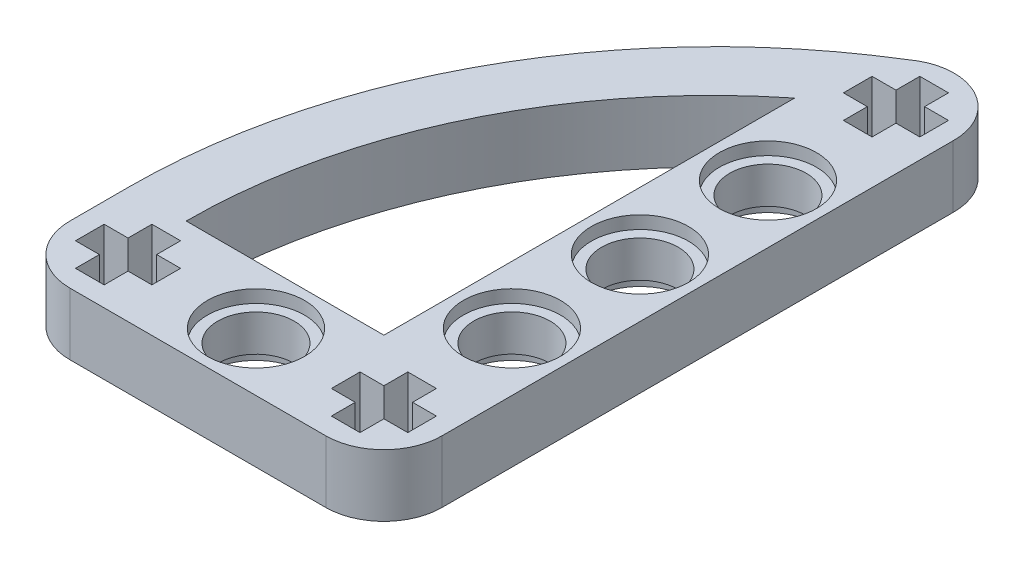
from build123d import *

# Parameters (mm, degrees)
SKETCH1_R           = 2.4
BOSS_EXTRUDE3_DEPTH = 3.9
SKETCH3_R           = 3.05
CUT_EXTRUDE16_DEPTH = 0.8
SKETCH4_R           = 3.05
CUT_EXTRUDE17_DEPTH = 0.8


with BuildPart() as part:
    # Sketch1 → Boss-Extrude3 (new body)
    with BuildSketch(Plane(origin=(0, 0, 0), x_dir=(1, 0, 0), z_dir=(0, 1, 0))):
        with BuildLine():
            Line((-8.030145899, -3.65), (8.039854101, -3.65))
            ThreePointArc((8.039854101, -3.65), (10.620793852, -2.580939751), (11.689854101, 0))
            Line((11.689854101, 0), (11.689854101, 32.1))
            ThreePointArc((11.689854101, 32.1), (9.706187522, 35.407989059), (5.862167957, 35.08980939))
            ThreePointArc((5.862167957, 35.08980939), (-6.996855856, 21.685482921), (-11.680145899, 3.710576637))
            Line((-11.680145899, 3.710576637), (-11.680145899, 0))
            ThreePointArc((-11.680145899, 0), (-10.611085651, -2.580939751), (-8.030145899, -3.65))
        make_face()
        with Locations((0.004854101, 0)):
            Circle(SKETCH1_R, mode=Mode.SUBTRACT)
        with Locations((8.039854101, 24.12)):
            Circle(SKETCH1_R, mode=Mode.SUBTRACT)
        with Locations((8.039854101, 16.08)):
            Circle(SKETCH1_R, mode=Mode.SUBTRACT)
        with Locations((8.039854101, 8.04)):
            Circle(SKETCH1_R, mode=Mode.SUBTRACT)
        with BuildLine():
            Line((-8.025815842, 3.649998716), (4.389854101, 3.649998716))
            Line((4.389854101, 3.649998716), (4.389854101, 29.443552649))
            ThreePointArc((4.389854101, 29.443552649), (-4.761047259, 17.963414157), (-8.025815842, 3.649998716))
        make_face(mode=Mode.SUBTRACT)
        Polygon((-8.930145899, 0.9), (-10.430145899, 0.9), (-10.430145899, -0.9), (-8.930145899, -0.9), (-8.930145899, -2.4), (-7.130145899, -2.4), (-7.130145899, -0.9), (-5.630145899, -0.9), (-5.630145899, 0.9), (-7.130145899, 0.9), (-7.130145899, 2.4), (-8.930145899, 2.4), align=None, mode=Mode.SUBTRACT)
        Polygon((10.439854101, -0.9), (8.939854101, -0.9), (8.939854101, -2.4), (7.139854101, -2.4), (7.139854101, -0.9), (5.639854101, -0.9), (5.639854101, 0.9), (7.139854101, 0.9), (7.139854101, 2.4), (8.939854101, 2.4), (8.939854101, 0.9), (10.439854101, 0.9), align=None, mode=Mode.SUBTRACT)
        Polygon((5.639854101, 33.06), (7.139854101, 33.06), (7.139854101, 34.56), (8.939854101, 34.56), (8.939854101, 33.06), (10.439854101, 33.06), (10.439854101, 31.26), (8.939854101, 31.26), (8.939854101, 29.76), (7.139854101, 29.76), (7.139854101, 31.26), (5.639854101, 31.26), align=None, mode=Mode.SUBTRACT)
    extrude(amount=BOSS_EXTRUDE3_DEPTH)

    # Sketch3 → Cut-Extrude16 (cut)
    with BuildSketch(Plane(origin=(0, 3.9, 0), x_dir=(1, 0, 0), z_dir=(0, 1, 0))):
        with Locations((0.004854101, 0)):
            Circle(SKETCH3_R)
        with Locations((8.039854101, 8.04)):
            Circle(SKETCH3_R)
        with Locations((8.039854101, 16.08)):
            Circle(SKETCH3_R)
        with Locations((8.039854101, 24.12)):
            Circle(SKETCH3_R)
    extrude(amount=-CUT_EXTRUDE16_DEPTH, mode=Mode.SUBTRACT)

    # Sketch4 → Cut-Extrude17 (cut)
    with BuildSketch(Plane.XZ):
        Circle(SKETCH4_R)
        with Locations((8.039854101, -8.04)):
            Circle(SKETCH4_R)
        with Locations((8.039854101, -16.08)):
            Circle(SKETCH4_R)
        with Locations((8.039854101, -24.12)):
            Circle(SKETCH4_R)
    extrude(amount=-CUT_EXTRUDE17_DEPTH, mode=Mode.SUBTRACT)


solid = part.part
